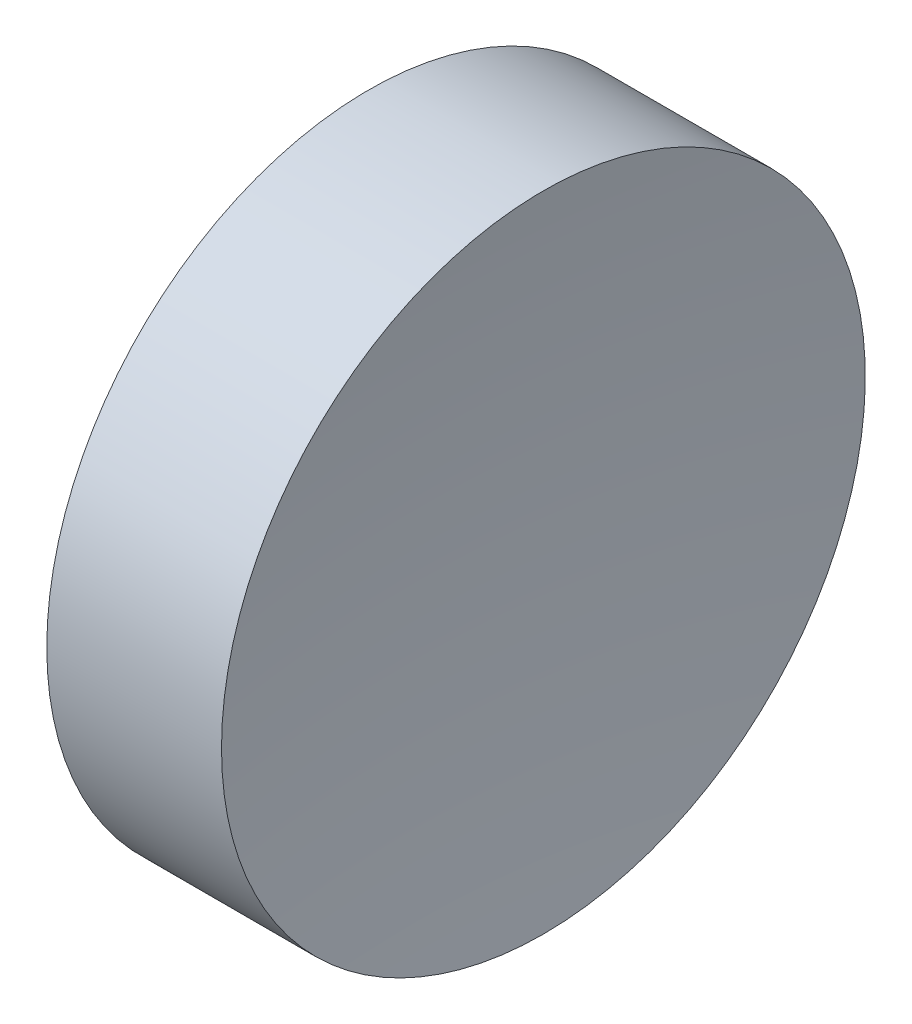
from build123d import *


with BuildPart() as part:
    # 草图1 → 旋转1 (revolve)
    with BuildSketch(Plane.XY, mode=Mode.PRIVATE) as revolve_1_sk:
        with BuildLine():
            Line((115.092655535, 69.378021123), (115.092655535, 81.878021123))
            Line((115.092655535, 81.878021123), (121.876981065, 81.878021123))
            ThreePointArc((121.876981065, 81.878021123), (121.288929306, 75.640312378), (121.092655229, 69.378021123))
            Line((121.092655229, 69.378021123), (115.092655535, 69.378021123))
        make_face()
    revolve(revolve_1_sk.sketch.rotate(Axis((108.985143002, 69.378021123, 0), (1, 0, 0)), 180), axis=Axis((108.985143002, 69.378021123, 0), (1, 0, 0)))  # turned: the seam where the file's is


solid = part.part
